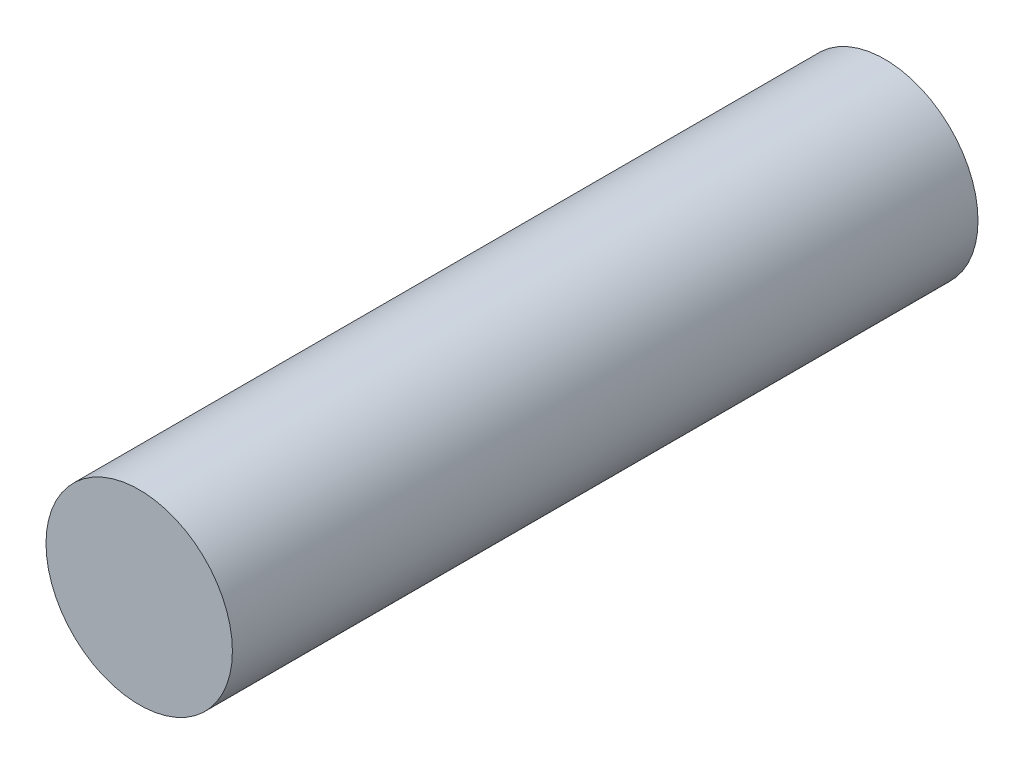
from build123d import *

# Parameters (mm, degrees)
SKETCH1_R           = 3.175
BOSS_EXTRUDE1_DEPTH = 12.7


with BuildPart() as part:
    # Sketch1 → Boss-Extrude1 (new body, symmetric)
    with BuildSketch(Plane.XY):
        Circle(SKETCH1_R)
    extrude(amount=BOSS_EXTRUDE1_DEPTH, both=True)


solid = part.part
